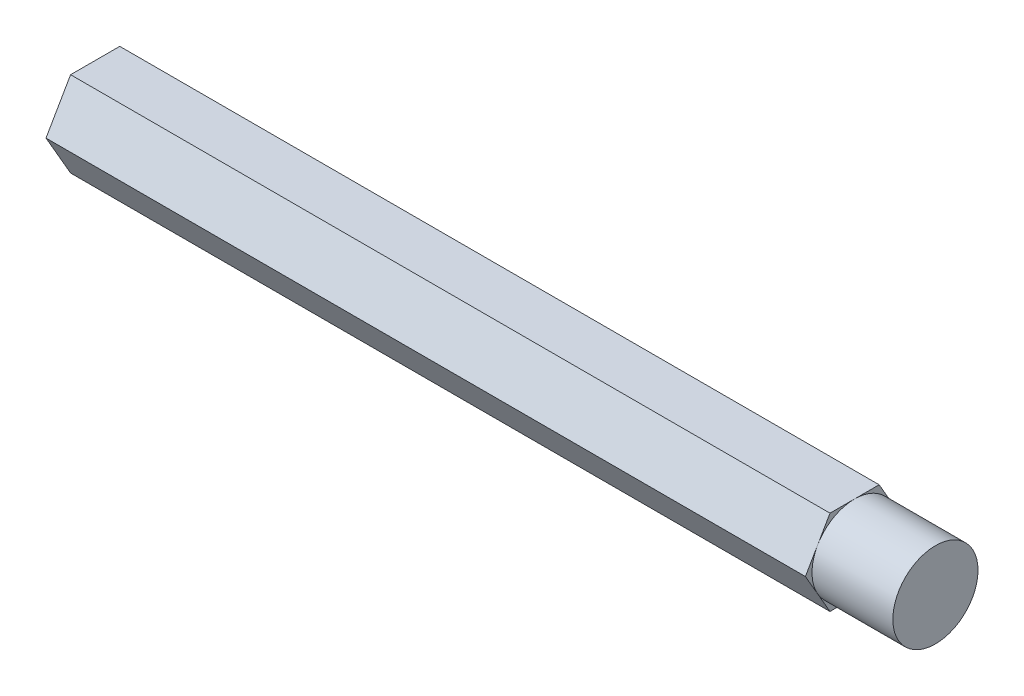
from build123d import *

# Parameters (mm, degrees)
BOSS_EXTRUDE1_DEPTH = 93.98
SKETCH2_R           = 5.499261314
SKETCH2_R_2         = 4.7625
CUT_EXTRUDE1_DEPTH  = 9.0424


with BuildPart() as part:
    # Sketch1 → Boss-Extrude1 (new body)
    with BuildSketch(Plane(origin=(0, 0, 0), x_dir=(0, 0, -1), z_dir=(1, 0, 0))):
        Polygon((-5.499261314, 0), (-2.749630657, -4.7625), (2.749630657, -4.7625), (5.499261314, 0), (2.749630657, 4.7625), (-2.749630657, 4.7625), align=None)
    extrude(amount=BOSS_EXTRUDE1_DEPTH)

    # Sketch2 → Cut-Extrude1 (cut)
    with BuildSketch(Plane(origin=(93.98, 0, 0), x_dir=(0, 0, -1), z_dir=(1, 0, 0))):
        Circle(SKETCH2_R)
        Circle(SKETCH2_R_2, mode=Mode.SUBTRACT)
    extrude(amount=-CUT_EXTRUDE1_DEPTH, mode=Mode.SUBTRACT)


solid = part.part
